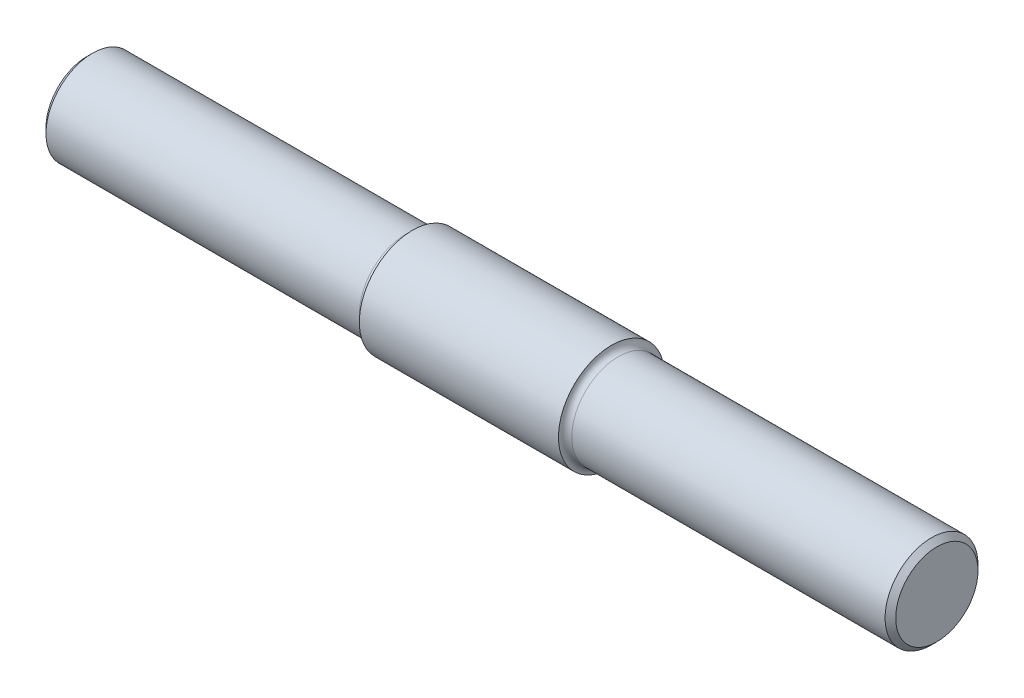
from build123d import *

# Parameters (mm, degrees)
CHAMFER1_SIZE = 0.635


with BuildPart() as part:
    # Sketch1 → Revolve1 (revolve)
    with BuildSketch(Plane.XY):
        with BuildLine():
            Line((-50.8, 0), (50.8, 0))
            Line((50.8, 0), (50.8, 5.55625))
            Line((50.8, 5.55625), (12.7, 5.55625))
            ThreePointArc((12.7, 5.55625), (12.138733992, 5.788733992), (11.90625, 6.35))
            Line((11.90625, 6.35), (-11.90625, 6.35))
            ThreePointArc((-11.90625, 6.35), (-12.138733992, 5.788733992), (-12.7, 5.55625))
            Line((-12.7, 5.55625), (-50.8, 5.55625))
            Line((-50.8, 5.55625), (-50.8, 0))
        make_face()
    revolve(axis=Axis((-50.8, 0, 0), (-1, 0, 0)))

    # Chamfer1
    chamfer1_edges = [part.edges().sort_by_distance(p)[0] for p in [
        (-50.8, -5.55625, 0),
        (50.8, -5.55625, 0),
    ]]
    chamfer(chamfer1_edges, length=CHAMFER1_SIZE)


solid = part.part
